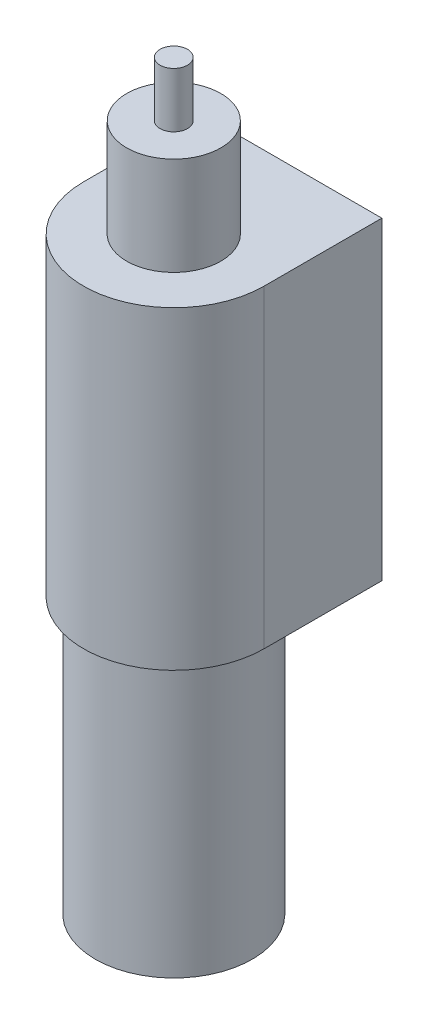
from build123d import *

# Parameters (mm, degrees)
ESBO_O2_R                = 2
RESSALTO_EXTRUS_O1_DEPTH = 15
ESBO_O3_R                = 1.2
RESSALTO_EXTRUS_O2_DEPTH = 2.5
ESBO_O4_R                = 0.35
RESSALTO_EXTRUS_O3_DEPTH = 1.4
ESBO_O5_R                = 2.3
ESBO_O5_R_2              = 2
RESSALTO_EXTRUS_O4_DEPTH = 8
ESBO_O6_R                = 2.3
ESBO_O6_W                = 4.6
ESBO_O6_H                = 3
RESSALTO_EXTRUS_O6_DEPTH = 8


with BuildPart() as part:
    # Esboço2 → Ressalto-extrusão1 (new body)
    with BuildSketch(Plane(origin=(0, 0, 0), x_dir=(1, 0, 0), z_dir=(0, 1, 0))):
        Circle(ESBO_O2_R)
    extrude(amount=RESSALTO_EXTRUS_O1_DEPTH)

    # Esboço3 → Ressalto-extrusão2 (add)
    with BuildSketch(Plane(origin=(0, 15, 0), x_dir=(1, 0, 0), z_dir=(0, 1, 0))):
        Circle(ESBO_O3_R)
    extrude(amount=RESSALTO_EXTRUS_O2_DEPTH)

    # Esboço4 → Ressalto-extrusão3 (add)
    with BuildSketch(Plane(origin=(0, 17.5, 0), x_dir=(1, 0, 0), z_dir=(0, 1, 0))):
        Circle(ESBO_O4_R)
    extrude(amount=RESSALTO_EXTRUS_O3_DEPTH)

    # Esboço5 → Ressalto-extrusão4 (add)
    with BuildSketch(Plane(origin=(0, 15, 0), x_dir=(1, 0, 0), z_dir=(0, 1, 0))):
        Circle(ESBO_O5_R)
        Circle(ESBO_O5_R_2, mode=Mode.SUBTRACT)
    extrude(amount=-RESSALTO_EXTRUS_O4_DEPTH)

    # Esboço6 → Ressalto-extrusão6 (add)
    with BuildSketch(Plane(origin=(0, 15, 0), x_dir=(1, 0, 0), z_dir=(0, 1, 0))):
        Circle(ESBO_O6_R)
        with Locations((0, 1.5)):
            Rectangle(ESBO_O6_W, ESBO_O6_H)
    extrude(amount=-RESSALTO_EXTRUS_O6_DEPTH)


solid = part.part
